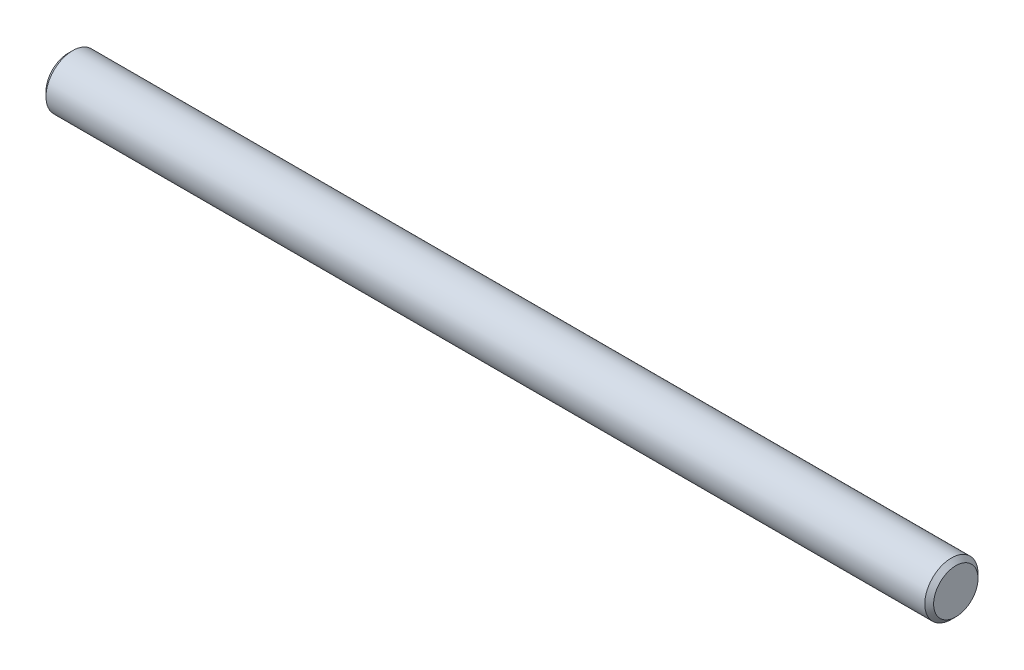
from build123d import *

# Parameters (mm, degrees)
SKETCH1_R           = 3
BOSS_EXTRUDE1_DEPTH = 50
CHAMFER1_SIZE       = 0.5


with BuildPart() as part:
    # Sketch1 → Boss-Extrude1 (new body, symmetric)
    with BuildSketch(Plane(origin=(0, 0, 0), x_dir=(0, 0, -1), z_dir=(1, 0, 0))):
        Circle(SKETCH1_R)
    extrude(amount=BOSS_EXTRUDE1_DEPTH, both=True)

    # Chamfer1
    chamfer1_edges = [part.edges().sort_by_distance(p)[0] for p in [
        (-50, 0, 3),
        (50, 0, 3),
    ]]
    chamfer(chamfer1_edges, length=CHAMFER1_SIZE)


solid = part.part
